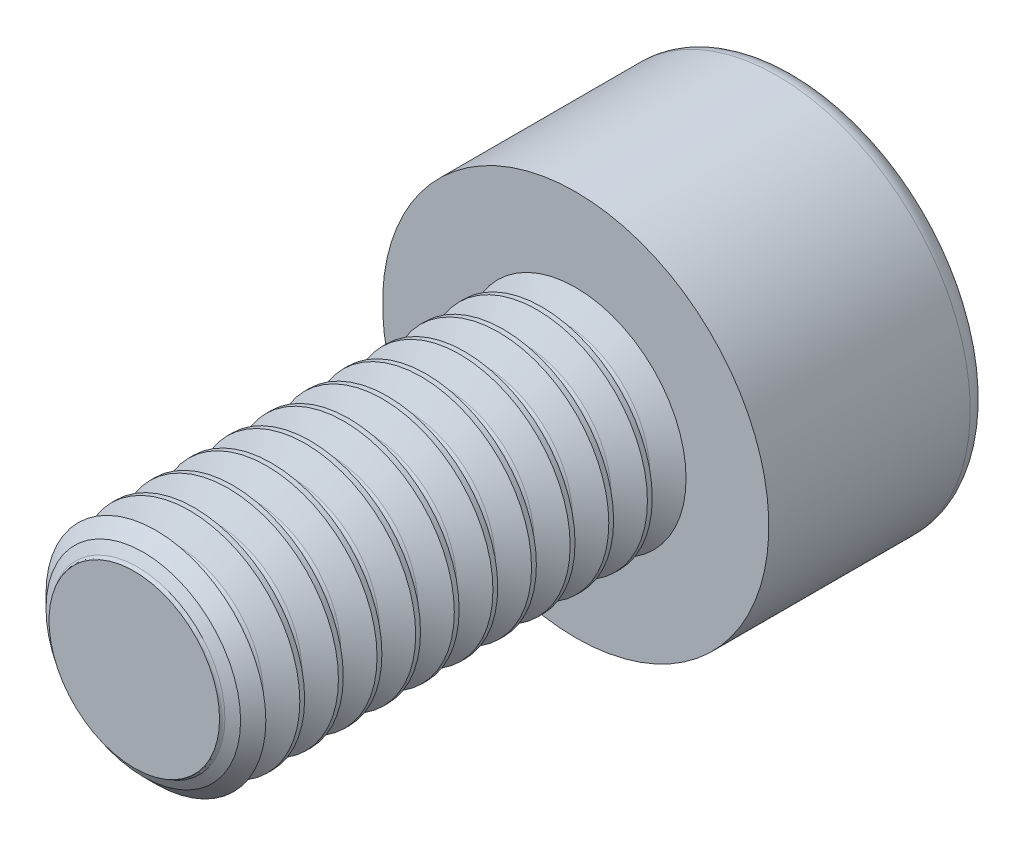
from build123d import *

# Parameters (mm, degrees)
SKETCH5_W           = 8
SKETCH5_H           = 2
THREAD_SIMPLE_COUNT = 12
THREAD_SIMPLE_PITCH = 0.7
SKETCH15_W          = 4
SKETCH15_H          = 3.5
CUT_HEAD_KEY_DEPTH  = 2


with BuildPart() as part:
    # Sketch5 → body (revolve)
    with BuildSketch(Plane(origin=(0, 0, 0), x_dir=(0, 0, -1), z_dir=(1, 0, 0))):
        with Locations((-4, 1)):
            Rectangle(SKETCH5_W, SKETCH5_H)
    revolve(axis=Axis((0, 0, 8), (0, 0, -1)))

    # Sketch11 → cut-chamfer-start (revolve, cut)
    with BuildSketch(Plane(origin=(0, 0, 0), x_dir=(0, 0, -1), z_dir=(1, 0, 0))):
        Polygon((-8, -2), (-8, -1.6), (-7.6, -2), align=None)
    revolve(axis=Axis((0, 0, 8), (0, 0, -1)), mode=Mode.SUBTRACT)

    # Sketch8 → thread-single (revolve, cut)
    with BuildSketch(Plane(origin=(0, 0, 0), x_dir=(0, 0, -1), z_dir=(1, 0, 0))):
        with BuildLine():
            Line((-0.6125, -2), (0, -2))
            Line((0, -2), (-0.240625, -1.583225274))
            ThreePointArc((-0.240625, -1.583225274), (-0.30625, -1.545336663), (-0.371875, -1.583225274))
            Line((-0.371875, -1.583225274), (-0.6125, -2))
        make_face()
    thread_single = revolve(axis=Axis((0, 0, 8), (0, 0, -1)), mode=Mode.SUBTRACT)

    # thread-simple: thread-single ×12
    with Locations(*[(0, 0, i * THREAD_SIMPLE_PITCH) for i in range(1, THREAD_SIMPLE_COUNT)]):
        add(thread_single, mode=Mode.SUBTRACT)

    # Sketch15 → body-head (revolve)
    with BuildSketch(Plane(origin=(0, 0, 0), x_dir=(0, 0, -1), z_dir=(1, 0, 0))):
        with Locations((2, -1.75)):
            Rectangle(SKETCH15_W, SKETCH15_H)
    revolve(axis=Axis((0, 0, -4), (0, 0, 1)))

    # Sketch19 → cut-head-profile (revolve, cut)
    with BuildSketch(Plane(origin=(0, 0, 0), x_dir=(0, 0, -1), z_dir=(1, 0, 0))):
        with BuildLine():
            Line((4, -3.5), (4, -3.15))
            ThreePointArc((4, -3.15), (3.897487373, -3.397487373), (3.65, -3.5))
            Line((3.65, -3.5), (4, -3.5))
        make_face()
    revolve(axis=Axis((0, 0, -4), (0, 0, 1)), mode=Mode.SUBTRACT)

    # Sketch25 → cut-head-key (cut)
    with BuildSketch(Plane.XY.offset(-4)):
        Polygon((0.866025404, 1.5), (-0.866025404, 1.5), (-1.732050808, 0), (-0.866025404, -1.5), (0.866025404, -1.5), (1.732050808, 0), align=None)
    extrude(amount=CUT_HEAD_KEY_DEPTH, mode=Mode.SUBTRACT)


solid = part.part
